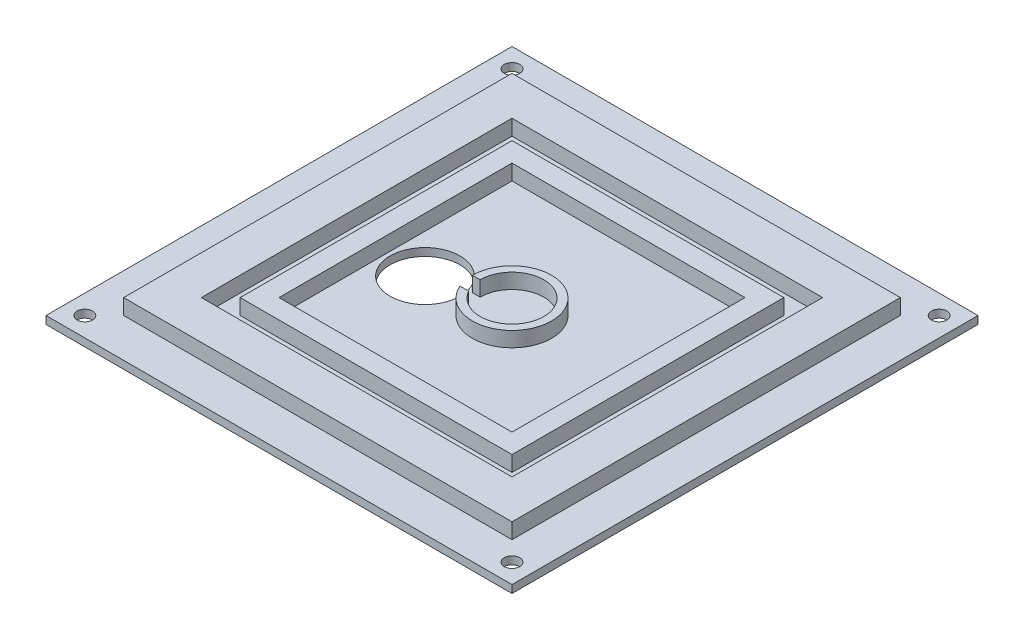
from build123d import *

# Parameters (mm, degrees)
SKETCH1_W           = 152.4
SKETCH1_H           = 152.4
BOSS_EXTRUDE1_DEPTH = 2.54
SKETCH2_W           = 127
SKETCH2_H           = 127
BOSS_EXTRUDE3_DEPTH = 5.08
SKETCH3_W           = 101.6
SKETCH3_H           = 101.6
CUT_EXTRUDE2_DEPTH  = 5.08
SKETCH5_W           = 88.9
SKETCH5_H           = 88.9
BOSS_EXTRUDE4_DEPTH = 5.08
SKETCH6_W           = 76.2
SKETCH6_H           = 76.2
CUT_EXTRUDE3_DEPTH  = 5.08
BOSS_EXTRUDE5_DEPTH = 2.794
SKETCH8_R           = 11.43
CUT_EXTRUDE4_DEPTH  = 108.882743755
SKETCH9_R           = 2.54
CUT_EXTRUDE5_DEPTH  = 108.882743755
BOSS_EXTRUDE6_DEPTH = 4.9276


with BuildPart() as part:
    # Sketch1 → Boss-Extrude1 (new body)
    with BuildSketch(Plane(origin=(0, 0, 0), x_dir=(1, 0, 0), z_dir=(0, 1, 0))):
        Rectangle(SKETCH1_W, SKETCH1_H)
    extrude(amount=-BOSS_EXTRUDE1_DEPTH)

    # Sketch2 → Boss-Extrude3 (add)
    with BuildSketch(Plane(origin=(0, 0, 0), x_dir=(1, 0, 0), z_dir=(0, 1, 0))):
        Rectangle(SKETCH2_W, SKETCH2_H)
    extrude(amount=BOSS_EXTRUDE3_DEPTH)

    # Sketch3 → Cut-Extrude2 (cut)
    with BuildSketch(Plane(origin=(0, 5.08, 0), x_dir=(1, 0, 0), z_dir=(0, 1, 0))):
        Rectangle(SKETCH3_W, SKETCH3_H)
    extrude(amount=-CUT_EXTRUDE2_DEPTH, mode=Mode.SUBTRACT)

    # Sketch5 → Boss-Extrude4 (add)
    with BuildSketch(Plane(origin=(0, 0, 0), x_dir=(1, 0, 0), z_dir=(0, 1, 0))):
        Rectangle(SKETCH5_W, SKETCH5_H)
    extrude(amount=BOSS_EXTRUDE4_DEPTH)

    # Sketch6 → Cut-Extrude3 (cut)
    with BuildSketch(Plane(origin=(0, 5.08, 0), x_dir=(1, 0, 0), z_dir=(0, 1, 0))):
        Rectangle(SKETCH6_W, SKETCH6_H)
    extrude(amount=-CUT_EXTRUDE3_DEPTH, mode=Mode.SUBTRACT)

    # Sketch7 → Boss-Extrude5 (add)
    with BuildSketch(Plane(origin=(0, 0, 0), x_dir=(1, 0, 0), z_dir=(0, 1, 0))):
        with BuildLine():
            Line((-10.414, 0), (-12.954, 0))
            ThreePointArc((-12.954, 0), (12.691940102, 2.592445263), (-11.916363371, -5.08))
            Line((-11.916363371, -5.08), (-9.090929325, -5.08))
            ThreePointArc((-9.090929325, -5.08), (10.077805664, 2.624734082), (-10.414, 0))
        make_face()
    extrude(amount=BOSS_EXTRUDE5_DEPTH)

    # Sketch8 → Cut-Extrude4 (cut, through all)
    with BuildSketch(Plane(origin=(0, 0, 0), x_dir=(1, 0, 0), z_dir=(0, 1, 0))):
        with Locations((-25.4, -3.048)):
            Circle(SKETCH8_R)
    extrude(amount=-CUT_EXTRUDE4_DEPTH, mode=Mode.SUBTRACT)

    # Sketch9 → Cut-Extrude5 (cut, through all)
    with BuildSketch(Plane(origin=(0, 0, 0), x_dir=(1, 0, 0), z_dir=(0, 1, 0))):
        with Locations((-69.85, -69.85)):
            Circle(SKETCH9_R)
        with Locations((69.85, -69.85)):
            Circle(SKETCH9_R)
        with Locations((69.85, 69.85)):
            Circle(SKETCH9_R)
        with Locations((-69.85, 69.85)):
            Circle(SKETCH9_R)
    extrude(amount=-CUT_EXTRUDE5_DEPTH, mode=Mode.SUBTRACT)

    # Sketch7_2 → Boss-Extrude6 (add)
    with BuildSketch(Plane(origin=(0, 0, 0), x_dir=(1, 0, 0), z_dir=(0, 1, 0))):
        with BuildLine():
            Line((-10.414, 0), (-12.954, 0))
            ThreePointArc((-12.954, 0), (12.691940102, 2.592445263), (-11.916363371, -5.08))
            Line((-11.916363371, -5.08), (-9.090929325, -5.08))
            ThreePointArc((-9.090929325, -5.08), (10.077805664, 2.624734082), (-10.414, 0))
        make_face()
    extrude(amount=BOSS_EXTRUDE6_DEPTH)


solid = part.part
